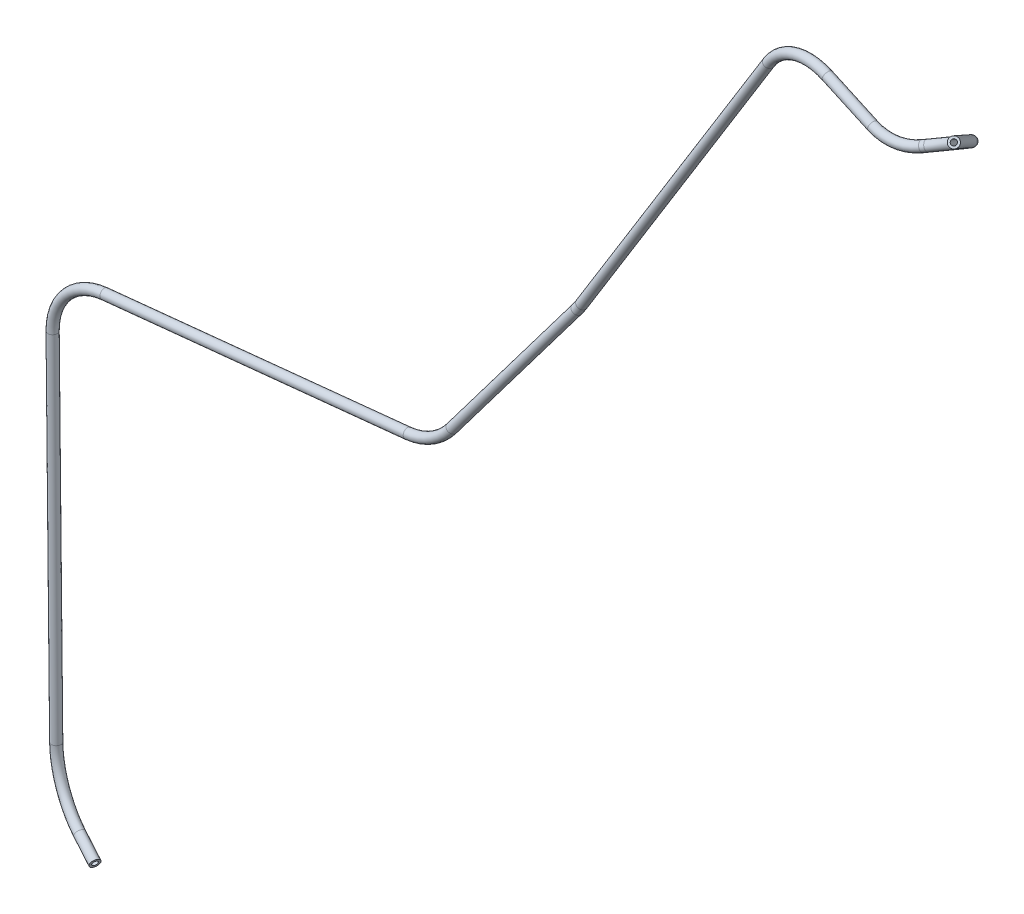
from build123d import *

# Parameters (mm, degrees)
SZKIC1_R   = 3.15
SZKIC1_R_2 = 1.75


with BuildPart() as part:
    # Wyciągnięcie po ścieżce1: sweep along a curve in space
    with BuildLine() as wyci_gni_cie_po_cie_ce1_path:
        Line((86.419880615, 600.104645999, 195.935969641), (51.962175993, 560.632152342, 150.138011064))
        ThreePointArc((51.962175993, 560.632152342, 150.138011064), (34.254965353, 545.138423284, 137.990209338), (11.319564386, 531.915361851, 138.526925645))
        Line((11.319564386, 531.915361851, 138.526925645), (8.687161303, 530.708410284, 139.327108373))
        ThreePointArc((-22.207606614, 528.522519036, 141.924690818), (-6.438680721, 526.890504984, 142.157130269), (8.687161303, 530.708410284, 139.327108373))
        Line((-22.207606614, 528.522519036, 141.924690818), (-56.782682029, 538.367162769, 137.861347312))
        ThreePointArc((-101.094924943, 521.466685422, 133.151988494), (-81.699600668, 537.276937776, 135.071230889), (-56.782682029, 538.367162769, 137.861347312))
        Line((-101.094924943, 521.466685422, 133.151988494), (-238.84987498, 305.883639321, 121.26437259))
        ThreePointArc((-242.134813599, 301.076171539, 121.37843068), (-240.456337572, 303.453021035, 121.225257584), (-238.84987498, 305.883639321, 121.26437259))
        Line((-242.134813599, 301.076171539, 121.37843068), (-315.612050211, 200.372888692, 132.073728464))
        ThreePointArc((-343.742816986, 184.143470648, 133.470842556), (-327.949460048, 189.296835255, 133.164754873), (-315.612050211, 200.372888692, 132.073728464))
        Line((-343.742816986, 184.143470648, 133.470842556), (-549.407992242, 161.902781967, 132.03528198))
        ThreePointArc((-549.407992242, 161.902781967, 132.03528198), (-574.878758367, 148.848403101, 131.759043903), (-585.104463836, 122.116625503, 131.442727408))
        Line((-585.104463836, 122.116625503, 131.442727408), (-584.971339317, -118.694827816, 129.141775489))
        ThreePointArc((-584.971339317, -118.694827816, 129.141775489), (-578.39008608, -141.28087938, 131.27073185), (-560.966387036, -156.027939679, 137.346421013))
        Line((-545.02875544, -162.671297, 142.970678291), (-560.966387036, -156.027939679, 137.346421013))
    # Szkic1 → Wyciągnięcie po ścieżce1 (sweep)
    with BuildSketch(Plane(origin=(86.419880615, 600.104645999, 195.935969641), x_dir=(-0.868090033, 0.35379433, 0.348208654), z_dir=(-0.495148194, -0.5672094, -0.658104675))):
        Circle(SZKIC1_R)
        Circle(SZKIC1_R_2, mode=Mode.SUBTRACT)
    sweep(path=wyci_gni_cie_po_cie_ce1_path.line)


solid = part.part
